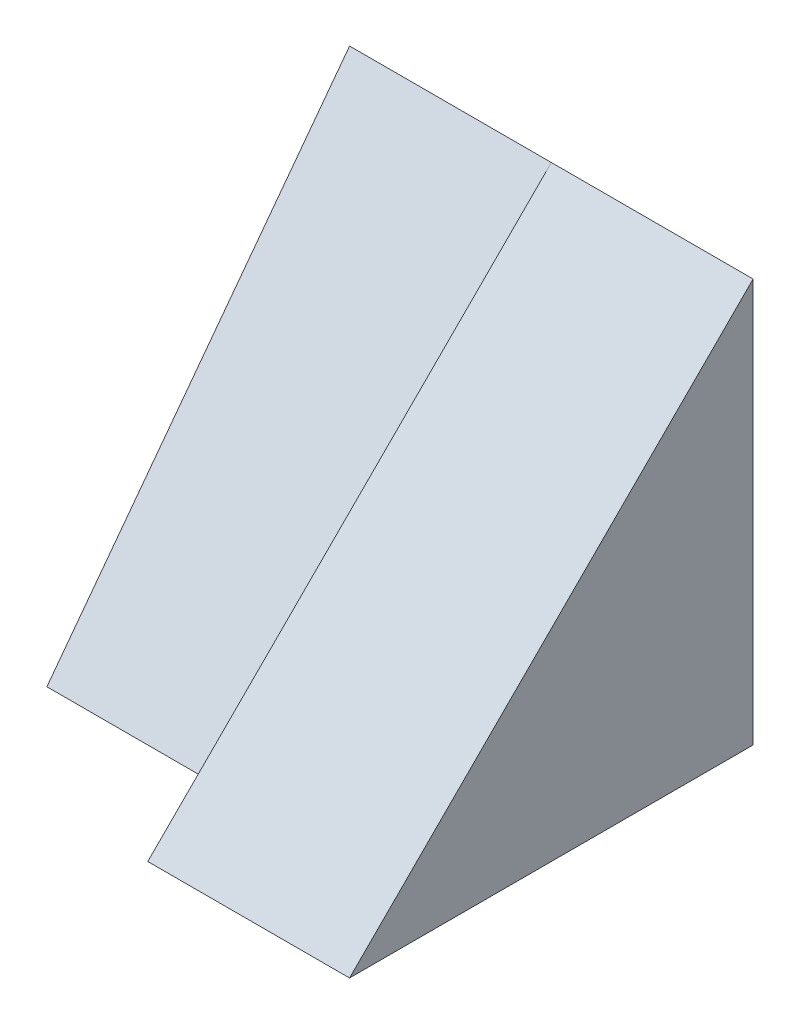
from build123d import *

# Parameters (mm, degrees)
SKETCH1_W           = 4
SKETCH1_H           = 4
BOSS_EXTRUDE1_DEPTH = 2
SKETCH2_W           = 3
SKETCH2_H           = 4
BOSS_EXTRUDE2_DEPTH = 2
CUT_EXTRUDE1_DEPTH  = 2
CUT_EXTRUDE2_DEPTH  = 2


with BuildPart() as part:
    # Sketch1 → Boss-Extrude1 (new body)
    with BuildSketch(Plane(origin=(0, 0, 0), x_dir=(0, 0, -1), z_dir=(1, 0, 0))):
        with Locations((2, 2)):
            Rectangle(SKETCH1_W, SKETCH1_H)
    extrude(amount=BOSS_EXTRUDE1_DEPTH)

    # Sketch2 → Boss-Extrude2 (add)
    with BuildSketch(Plane.ZY):
        with Locations((-2.5, 2)):
            Rectangle(SKETCH2_W, SKETCH2_H)
    extrude(amount=BOSS_EXTRUDE2_DEPTH)

    # Sketch3 → Cut-Extrude1 (cut)
    with BuildSketch(Plane(origin=(2, 0, 0), x_dir=(0, 0, -1), z_dir=(1, 0, 0))):
        Polygon((0, 0), (4, 4), (0, 4), align=None)
    extrude(amount=-CUT_EXTRUDE1_DEPTH, mode=Mode.SUBTRACT)

    # Sketch4 → Cut-Extrude2 (cut)
    with BuildSketch(Plane.ZY.offset(2)):
        Polygon((-1, 0), (-4, 4), (-1, 4), align=None)
    extrude(amount=-CUT_EXTRUDE2_DEPTH, mode=Mode.SUBTRACT)


solid = part.part
